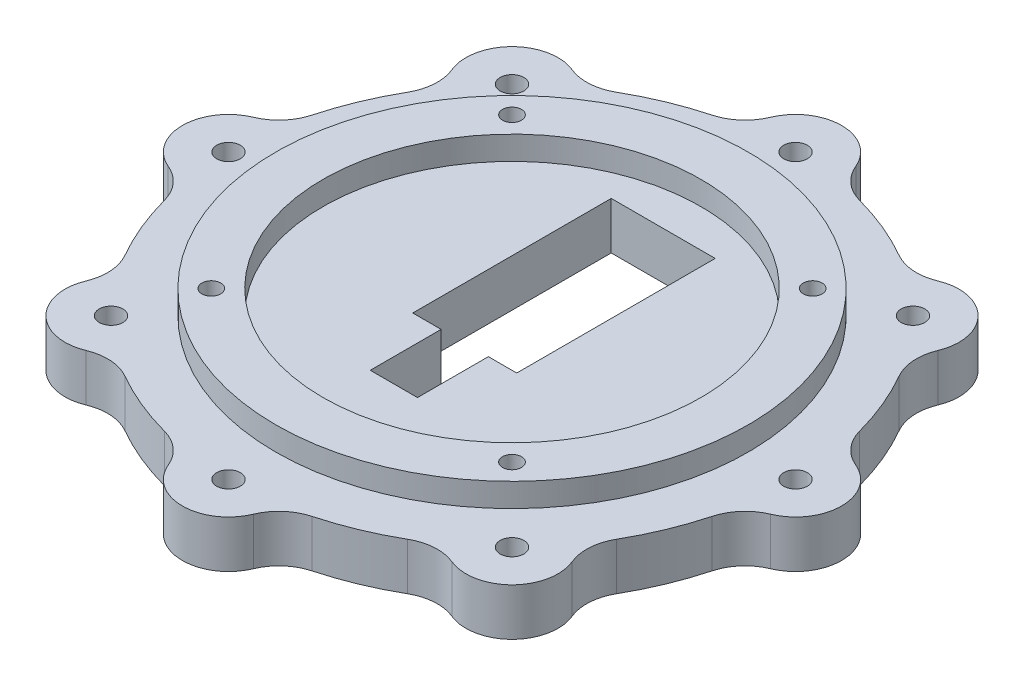
from build123d import *

# Parameters (mm, degrees)
CROQUIS1_W              = 22
CROQUIS1_H              = 42
CROQUIS1_R              = 2.5
CROQUIS1_R_2            = 2
SALIENTE_EXTRUIR1_DEPTH = 10
REDONDEO1_R             = 10
CROQUIS2_R              = 5
CORTAR_EXTRUIR1_DEPTH   = 5
CROQUIS3_W              = 10
CROQUIS3_H              = 15
CORTAR_EXTRUIR2_DEPTH   = 10
CROQUIS4_R              = 50
CROQUIS4_R_2            = 40
CROQUIS4_R_3            = 2
SALIENTE_EXTRUIR2_DEPTH = 5


with BuildPart() as part:
    # Croquis1 → Saliente-Extruir1 (new body)
    with BuildSketch(Plane(origin=(0, 0, 0), x_dir=(1, 0, 0), z_dir=(0, 1, 0))):
        with BuildLine():
            ThreePointArc((-9.717764093, 59.2078125), (-22.961005942, 55.432771951), (-34.99474883, 48.737742606))
            ThreePointArc((-34.99474883, 48.737742606), (-49.320697988, 49.320697988), (-48.737742606, 34.99474883))
            ThreePointArc((-48.737742606, 34.99474883), (-55.432771951, 22.961005942), (-59.2078125, 9.717764093))
            ThreePointArc((-59.2078125, 9.717764093), (-69.75, 0), (-59.2078125, -9.717764093))
            ThreePointArc((-59.2078125, -9.717764093), (-55.432771951, -22.961005942), (-48.737742606, -34.99474883))
            ThreePointArc((-48.737742606, -34.99474883), (-49.320697988, -49.320697988), (-34.99474883, -48.737742606))
            ThreePointArc((-34.99474883, -48.737742606), (-22.961005942, -55.432771951), (-9.717764093, -59.2078125))
            ThreePointArc((-9.717764093, -59.2078125), (0, -69.75), (9.717764093, -59.2078125))
            ThreePointArc((9.717764093, -59.2078125), (22.961005942, -55.432771951), (34.99474883, -48.737742606))
            ThreePointArc((34.99474883, -48.737742606), (49.320697988, -49.320697988), (48.737742606, -34.99474883))
            ThreePointArc((48.737742606, -34.99474883), (55.432771951, -22.961005942), (59.2078125, -9.717764093))
            ThreePointArc((59.2078125, -9.717764093), (69.75, 0), (59.2078125, 9.717764093))
            ThreePointArc((59.2078125, 9.717764093), (55.432771951, 22.961005942), (48.737742606, 34.99474883))
            ThreePointArc((48.737742606, 34.99474883), (49.320697988, 49.320697988), (34.99474883, 48.737742606))
            ThreePointArc((34.99474883, 48.737742606), (22.961005942, 55.432771951), (9.717764093, 59.2078125))
            ThreePointArc((9.717764093, 59.2078125), (0, 69.75), (-9.717764093, 59.2078125))
        make_face()
        with Locations((0, 11)):
            Rectangle(CROQUIS1_W, CROQUIS1_H, mode=Mode.SUBTRACT)
        with Locations((0, 60)):
            Circle(CROQUIS1_R, mode=Mode.SUBTRACT)
        with Locations((-42.426406871, 42.426406871)):
            Circle(CROQUIS1_R, mode=Mode.SUBTRACT)
        with Locations((-60, 0)):
            Circle(CROQUIS1_R, mode=Mode.SUBTRACT)
        with Locations((-42.426406871, -42.426406871)):
            Circle(CROQUIS1_R, mode=Mode.SUBTRACT)
        with Locations((0, -60)):
            Circle(CROQUIS1_R, mode=Mode.SUBTRACT)
        with Locations((42.426406871, -42.426406871)):
            Circle(CROQUIS1_R, mode=Mode.SUBTRACT)
        with Locations((60, 0)):
            Circle(CROQUIS1_R, mode=Mode.SUBTRACT)
        with Locations((42.426406871, 42.426406871)):
            Circle(CROQUIS1_R, mode=Mode.SUBTRACT)
        with Locations((31.819805153, 31.819805153)):
            Circle(CROQUIS1_R_2, mode=Mode.SUBTRACT)
        with Locations((31.819805153, -31.819805153)):
            Circle(CROQUIS1_R_2, mode=Mode.SUBTRACT)
        with Locations((-31.819805153, -31.819805153)):
            Circle(CROQUIS1_R_2, mode=Mode.SUBTRACT)
        with Locations((-31.819805153, 31.819805153)):
            Circle(CROQUIS1_R_2, mode=Mode.SUBTRACT)
    extrude(amount=SALIENTE_EXTRUIR1_DEPTH)

    # Redondeo1
    redondeo1_edges = [part.edges().sort_by_distance(p)[0] for p in [
        (-34.99474883, 5, -48.737742606),
        (-9.717764093, 5, -59.2078125),
        (9.717764093, 5, -59.2078125),
        (34.99474883, 5, -48.737742606),
        (48.737742606, 5, -34.99474883),
        (59.2078125, 5, -9.717764093),
        (59.2078125, 5, 9.717764093),
        (48.737742606, 5, 34.99474883),
        (34.99474883, 5, 48.737742606),
        (9.717764093, 5, 59.2078125),
        (-9.717764093, 5, 59.2078125),
        (-34.99474883, 5, 48.737742606),
        (-48.737742606, 5, 34.99474883),
        (-59.2078125, 5, 9.717764093),
        (-59.2078125, 5, -9.717764093),
        (-48.737742606, 5, -34.99474883),
    ]]
    fillet(redondeo1_edges, radius=REDONDEO1_R)

    # Croquis2 → Cortar-Extruir1 (cut)
    with BuildSketch(Plane.XZ):
        with Locations((31.819805153, 31.819805153)):
            Circle(CROQUIS2_R)
        with Locations((31.819805153, -31.819805153)):
            Circle(CROQUIS2_R)
        with Locations((-31.819805153, -31.819805153)):
            Circle(CROQUIS2_R)
        with Locations((-31.819805153, 31.819805153)):
            Circle(CROQUIS2_R)
    extrude(amount=-CORTAR_EXTRUIR1_DEPTH, mode=Mode.SUBTRACT)

    # Croquis3 → Cortar-Extruir2 (cut)
    with BuildSketch(Plane(origin=(0, 10, 0), x_dir=(1, 0, 0), z_dir=(0, 1, 0))):
        with Locations((0, -17.5)):
            Rectangle(CROQUIS3_W, CROQUIS3_H)
    extrude(amount=-CORTAR_EXTRUIR2_DEPTH, mode=Mode.SUBTRACT)

    # Croquis4 → Saliente-Extruir2 (add)
    with BuildSketch(Plane(origin=(0, 10, 0), x_dir=(1, 0, 0), z_dir=(0, 1, 0))):
        Circle(CROQUIS4_R)
        Circle(CROQUIS4_R_2, mode=Mode.SUBTRACT)
        with Locations((-31.819805153, 31.819805153)):
            Circle(CROQUIS4_R_3, mode=Mode.SUBTRACT)
        with Locations((31.819805153, 31.819805153)):
            Circle(CROQUIS4_R_3, mode=Mode.SUBTRACT)
        with Locations((31.819805153, -31.819805153)):
            Circle(CROQUIS4_R_3, mode=Mode.SUBTRACT)
        with Locations((-31.819805153, -31.819805153)):
            Circle(CROQUIS4_R_3, mode=Mode.SUBTRACT)
    extrude(amount=SALIENTE_EXTRUIR2_DEPTH)


solid = part.part
